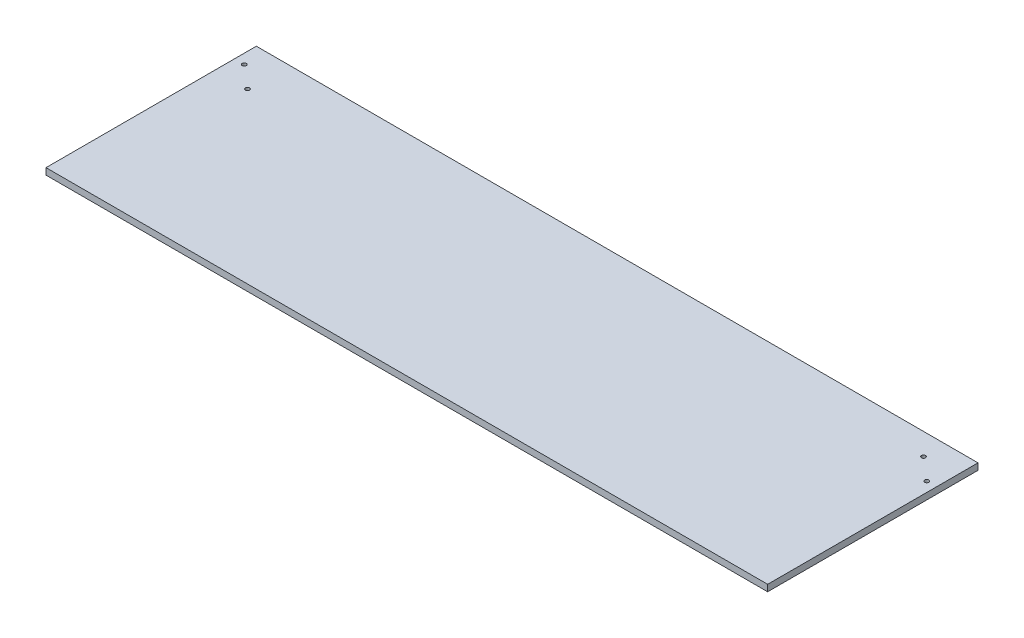
from build123d import *

# Parameters (mm, degrees)
SKETCH2_W                    = 703.33
SKETCH2_H                    = 205
BOSS_EXTRUDE1_DEPTH          = 6.35
F_4_0_4_DIAMETER_HOLE1_D     = 4
F_4_0_4_DIAMETER_HOLE1_DEPTH = 10
F_4_0_4_DIAMETER_HOLE1_TIP   = 1.201721238


with BuildPart() as part:
    # Sketch2 → Boss-Extrude1 (new body)
    with BuildSketch(Plane(origin=(0, 0, 0), x_dir=(1, 0, 0), z_dir=(0, 1, 0))):
        with Locations((351.665, 102.5)):
            Rectangle(SKETCH2_W, SKETCH2_H)
    extrude(amount=BOSS_EXTRUDE1_DEPTH)

    # Ø4.0 (4) Diameter Hole1
    with Locations(Plane(origin=(351.667298108, 6.35, -173.242751044), x_dir=(-1, 0, 0), z_dir=(0, 1, 0))):
        with Locations((-342.137701892, 8.642751044), (-319.912701892, -10.407248956), (319.912701892, 8.642751044), (342.137701892, -10.407248956)):
            Hole(F_4_0_4_DIAMETER_HOLE1_D / 2, depth=F_4_0_4_DIAMETER_HOLE1_DEPTH)
            with Locations((0, 0, -(F_4_0_4_DIAMETER_HOLE1_DEPTH + F_4_0_4_DIAMETER_HOLE1_TIP / 2))):  # 118° drill point
                Cone(0, F_4_0_4_DIAMETER_HOLE1_D / 2, F_4_0_4_DIAMETER_HOLE1_TIP, mode=Mode.SUBTRACT)


solid = part.part
